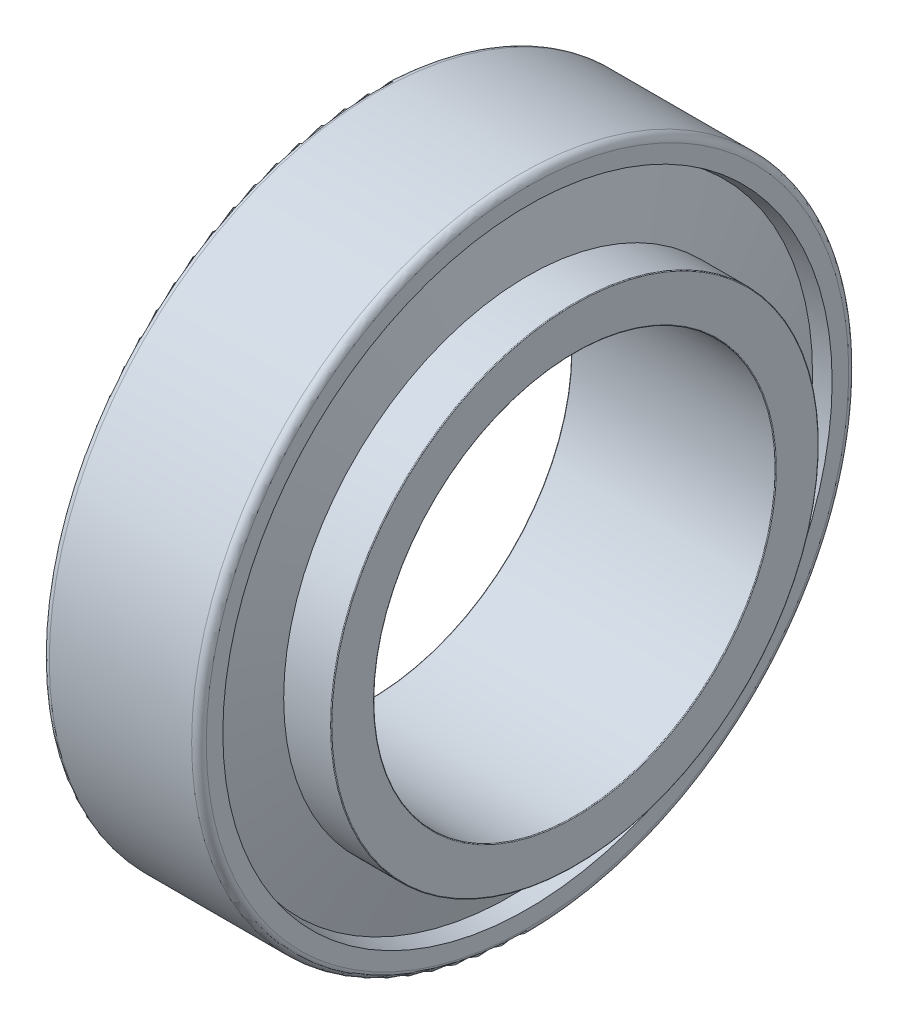
from build123d import *


with BuildPart() as part:
    # Эскиз1 → Повернуть1 (revolve)
    with BuildSketch(Plane.XY):
        with BuildLine():
            Line((5.673835343, 75.737111548), (0, 74.5635))
            Line((0, 74.5635), (0, 88))
            ThreePointArc((0, 88), (0.585786438, 89.414213562), (2, 90))
            Line((2, 90), (41, 90))
            ThreePointArc((41, 90), (42.414213562, 89.414213562), (43, 88))
            Line((43, 88), (43, 83.457888633))
            Line((43, 83.457888633), (38.55204573, 82.537845984))
            Line((38.55204573, 82.537845984), (43, 66.589154016))
            Line((43, 66.589154016), (43, 66.789154016))
            Line((43, 66.789154016), (55.8, 66.789154016))
            ThreePointArc((55.8, 66.789154016), (55.941421356, 66.730575372), (56, 66.589154016))
            Line((56, 66.589154016), (56, 55.2))
            ThreePointArc((56, 55.2), (55.941421356, 55.058578644), (55.8, 55))
            Line((55.8, 55), (0.2, 55))
            ThreePointArc((0.2, 55), (0.058578644, 55.058578644), (0, 55.2))
            Line((0, 55.2), (0, 55.392870878))
            Line((0, 55.392870878), (11.347670687, 55.392870878))
            Line((11.347670687, 55.392870878), (5.673835343, 75.737111548))
        make_face()
    revolve(axis=Axis((-882.527700014, 0, 0), (1, 0, 0)))


solid = part.part
